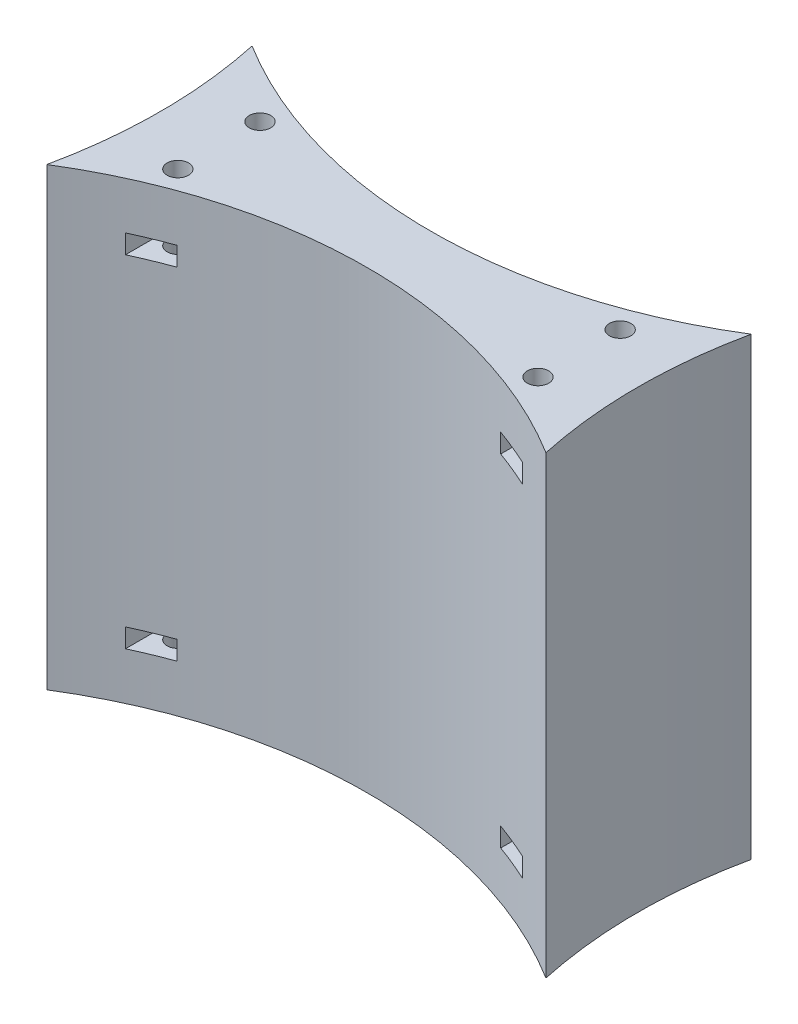
from build123d import *

# Parameters (mm, degrees)
SALIENTE_EXTRUIR1_DEPTH      = 36
SALIENTE_EXTRUIR1_DEPTH_BACK = 36
CROQUIS2_R                   = 1.7
CORTAR_EXTRUIR1_DEPTH        = 30
CORTAR_EXTRUIR2_DEPTH        = 1.5
SIMETR_A2_COPY_1_SKETCH_R    = 1.7
SIMETR_A2_COPY_1_DEPTH       = 30
SIMETR_A2_COPY_2_DEPTH       = 1.5
SIMETR_A3_COPY_1_SKETCH_R    = 1.7
SIMETR_A3_COPY_1_DEPTH       = 30
SIMETR_A3_COPY_2_DEPTH       = 1.5
SIMETR_A3_COPY_3_SKETCH_R    = 1.7
SIMETR_A3_COPY_3_DEPTH       = 30
SIMETR_A3_COPY_4_DEPTH       = 1.5
SIMETR_A3_COPY_5_SKETCH_R    = 1.7
SIMETR_A3_COPY_5_DEPTH       = 30
SIMETR_A3_COPY_6_DEPTH       = 1.5


with BuildPart() as part:
    # Croquis1 → Saliente-Extruir1 (new body, two sides)
    with BuildSketch(Plane(origin=(0, 0, 0), x_dir=(1, 0, 0), z_dir=(0, 1, 0))) as saliente_extruir1_sk:
        with BuildLine():
            ThreePointArc((-39.5, 16.244608071), (0, 5), (39.5, 16.244608071))
            ThreePointArc((39.5, 16.244608071), (37.772172817, 0), (39.5, -16.244608071))
            ThreePointArc((39.5, -16.244608071), (0, -5), (-39.5, -16.244608071))
            ThreePointArc((-39.5, -16.244608071), (-37.772172817, 0), (-39.5, 16.244608071))
        make_face()
    extrude(amount=SALIENTE_EXTRUIR1_DEPTH)
    extrude(saliente_extruir1_sk.sketch, amount=-SALIENTE_EXTRUIR1_DEPTH_BACK)

    # Croquis2 → Cortar-Extruir1 (cut)
    with BuildSketch(Plane(origin=(0, 36, 0), x_dir=(1, 0, 0), z_dir=(0, 1, 0))):
        with Locations((28.5, -6.5)):
            Circle(CROQUIS2_R)
    cortar_extruir1 = extrude(amount=-CORTAR_EXTRUIR1_DEPTH, mode=Mode.SUBTRACT)

    # Croquis3 → Cortar-Extruir2 (cut, symmetric)
    with BuildSketch(Plane(origin=(0, 27, 0), x_dir=(1, 0, 0), z_dir=(0, 1, 0))):
        Polygon((25.598814897, -8.175), (25.598814897, -14.825), (31.401185103, -14.825), (31.401185103, -8.175), (31.401185103, -4.825), (28.5, -3.15), (25.598814897, -4.825), align=None)
    cortar_extruir2 = extrude(amount=CORTAR_EXTRUIR2_DEPTH, both=True, mode=Mode.SUBTRACT)

    # Simetr_a1: Cortar-Extruir1, Cortar-Extruir2 across plane
    add(cortar_extruir1.mirror(Plane.XY), mode=Mode.SUBTRACT)
    add(cortar_extruir2.mirror(Plane.XY), mode=Mode.SUBTRACT)

    # Simetr_a2: Cortar-Extruir1, Cortar-Extruir2 across plane
    add(cortar_extruir1.mirror(Plane(origin=(0, 0, 0), x_dir=(0, 0, 1), z_dir=(1, 0, 0))), mode=Mode.SUBTRACT)
    add(cortar_extruir2.mirror(Plane(origin=(0, 0, 0), x_dir=(0, 0, 1), z_dir=(1, 0, 0))), mode=Mode.SUBTRACT)

    # Simetr_a2 copy 1 sketch → Simetr_a2 copy 1 (cut)
    with BuildSketch(Plane(origin=(0, 36, 0), x_dir=(-1, 0, 0), z_dir=(0, 1, 0))):
        with Locations((28.5, -6.5)):
            Circle(SIMETR_A2_COPY_1_SKETCH_R)
    extrude(amount=-SIMETR_A2_COPY_1_DEPTH, mode=Mode.SUBTRACT)

    # Simetr_a2 copy 2 sketch → Simetr_a2 copy 2 (cut, symmetric)
    with BuildSketch(Plane(origin=(0, 27, 0), x_dir=(-1, 0, 0), z_dir=(0, 1, 0))):
        Polygon((25.598814897, -8.175), (25.598814897, -14.825), (31.401185103, -14.825), (31.401185103, -8.175), (31.401185103, -4.825), (28.5, -3.15), (25.598814897, -4.825), align=None)
    extrude(amount=SIMETR_A2_COPY_2_DEPTH, both=True, mode=Mode.SUBTRACT)

    # Simetr_a3: Cortar-Extruir1, Cortar-Extruir2 across plane
    add(cortar_extruir1.mirror(Plane.ZX), mode=Mode.SUBTRACT)
    add(cortar_extruir2.mirror(Plane.ZX), mode=Mode.SUBTRACT)

    # Simetr_a3 copy 1 sketch → Simetr_a3 copy 1 (cut)
    with BuildSketch(Plane(origin=(0, -36, 0), x_dir=(-1, 0, 0), z_dir=(0, -1, 0))):
        with Locations((28.5, -6.5)):
            Circle(SIMETR_A3_COPY_1_SKETCH_R)
    extrude(amount=-SIMETR_A3_COPY_1_DEPTH, mode=Mode.SUBTRACT)

    # Simetr_a3 copy 2 sketch → Simetr_a3 copy 2 (cut, symmetric)
    with BuildSketch(Plane(origin=(0, -27, 0), x_dir=(-1, 0, 0), z_dir=(0, -1, 0))):
        Polygon((25.598814897, -8.175), (25.598814897, -14.825), (31.401185103, -14.825), (31.401185103, -8.175), (31.401185103, -4.825), (28.5, -3.15), (25.598814897, -4.825), align=None)
    extrude(amount=SIMETR_A3_COPY_2_DEPTH, both=True, mode=Mode.SUBTRACT)

    # Simetr_a3 copy 3 sketch → Simetr_a3 copy 3 (cut)
    with BuildSketch(Plane(origin=(0, -36, 0), x_dir=(-1, 0, 0), z_dir=(0, -1, 0))):
        with Locations((28.5, 6.5)):
            Circle(SIMETR_A3_COPY_3_SKETCH_R)
    extrude(amount=-SIMETR_A3_COPY_3_DEPTH, mode=Mode.SUBTRACT)

    # Simetr_a3 copy 4 sketch → Simetr_a3 copy 4 (cut, symmetric)
    with BuildSketch(Plane(origin=(0, -27, 0), x_dir=(-1, 0, 0), z_dir=(0, -1, 0))):
        Polygon((25.598814897, 8.175), (25.598814897, 14.825), (31.401185103, 14.825), (31.401185103, 8.175), (31.401185103, 4.825), (28.5, 3.15), (25.598814897, 4.825), align=None)
    extrude(amount=SIMETR_A3_COPY_4_DEPTH, both=True, mode=Mode.SUBTRACT)

    # Simetr_a3 copy 5 sketch → Simetr_a3 copy 5 (cut)
    with BuildSketch(Plane.XZ.offset(36)):
        with Locations((28.5, -6.5)):
            Circle(SIMETR_A3_COPY_5_SKETCH_R)
    extrude(amount=-SIMETR_A3_COPY_5_DEPTH, mode=Mode.SUBTRACT)

    # Simetr_a3 copy 6 sketch → Simetr_a3 copy 6 (cut, symmetric)
    with BuildSketch(Plane.XZ.offset(27)):
        Polygon((25.598814897, -8.175), (25.598814897, -14.825), (31.401185103, -14.825), (31.401185103, -8.175), (31.401185103, -4.825), (28.5, -3.15), (25.598814897, -4.825), align=None)
    extrude(amount=SIMETR_A3_COPY_6_DEPTH, both=True, mode=Mode.SUBTRACT)


solid = part.part
